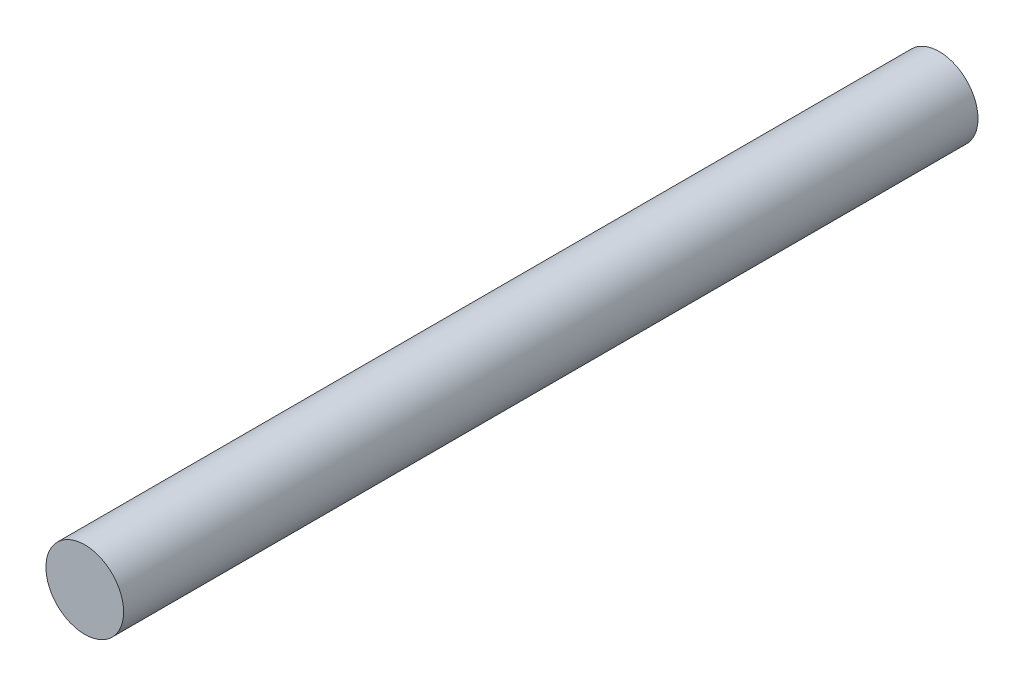
from build123d import *

# Parameters (mm, degrees)
SKETCH1_R           = 25.4
BOSS_EXTRUDE1_DEPTH = 558.8


with BuildPart() as part:
    # Sketch1 → Boss-Extrude1 (new body)
    with BuildSketch(Plane.XY):
        with Locations((0, -2.032338723)):
            Circle(SKETCH1_R)
    extrude(amount=BOSS_EXTRUDE1_DEPTH)


solid = part.part
